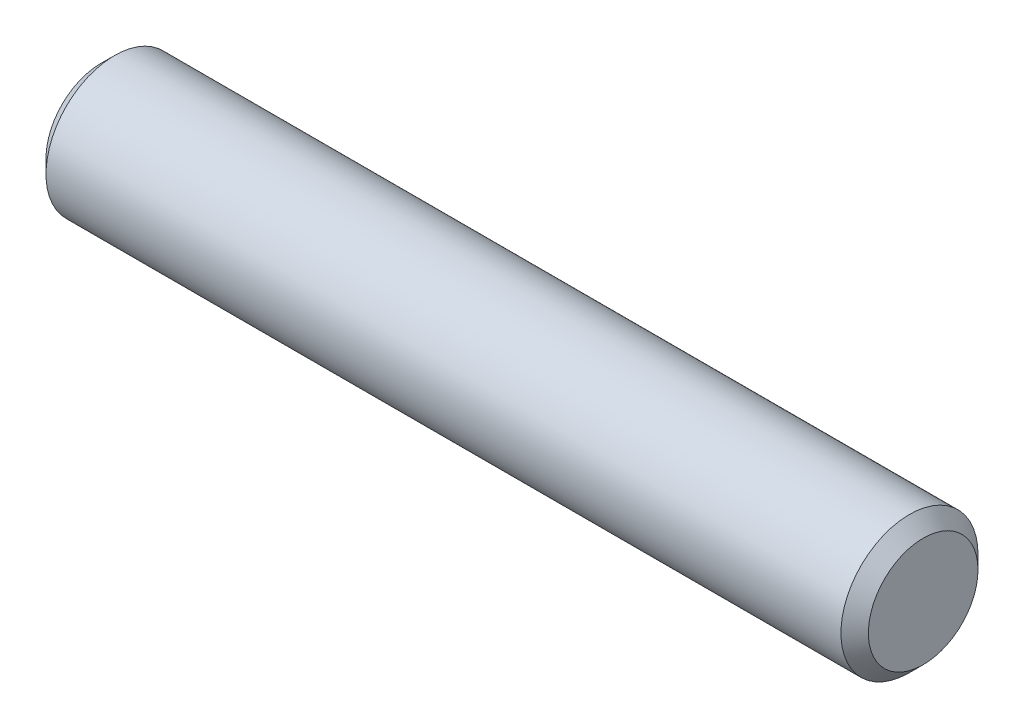
from build123d import *

# Parameters (mm, degrees)
SKETCH2_R           = 0.79375
EXTRUDE1_DEPTH      = 4.7625
EXTRUDE1_DEPTH_BACK = 4.7625
CHAMFER1_SIZE       = 0.15875


with BuildPart() as part:
    # Sketch2 → Extrude1 (new body, two sides)
    with BuildSketch(Plane(origin=(0, 0, 0), x_dir=(0, 0, -1), z_dir=(1, 0, 0))) as extrude1_sk:
        Circle(SKETCH2_R)
    extrude(amount=EXTRUDE1_DEPTH)
    extrude(extrude1_sk.sketch, amount=-EXTRUDE1_DEPTH_BACK)

    # Chamfer1
    chamfer1_edges = [part.edges().sort_by_distance(p)[0] for p in [
        (-4.7625, 0, 0.79375),
        (4.7625, 0, 0.79375),
    ]]
    chamfer(chamfer1_edges, length=CHAMFER1_SIZE)


solid = part.part
